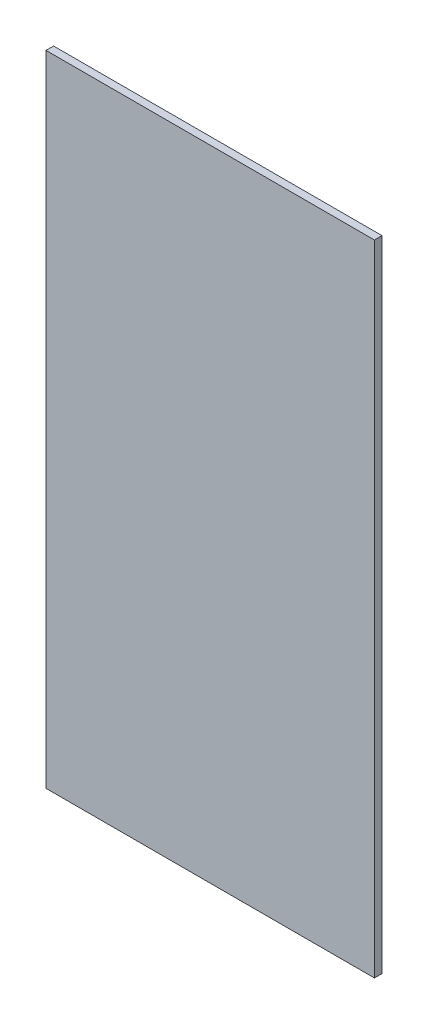
from build123d import *

# Parameters (mm, degrees)
SKETCH1_W           = 260
SKETCH1_H           = 506
BOSS_EXTRUDE1_DEPTH = 6


with BuildPart() as part:
    # Sketch1 → Boss-Extrude1 (new body)
    with BuildSketch(Plane.XY):
        with Locations((130, 253)):
            Rectangle(SKETCH1_W, SKETCH1_H)
    extrude(amount=BOSS_EXTRUDE1_DEPTH)


solid = part.part
